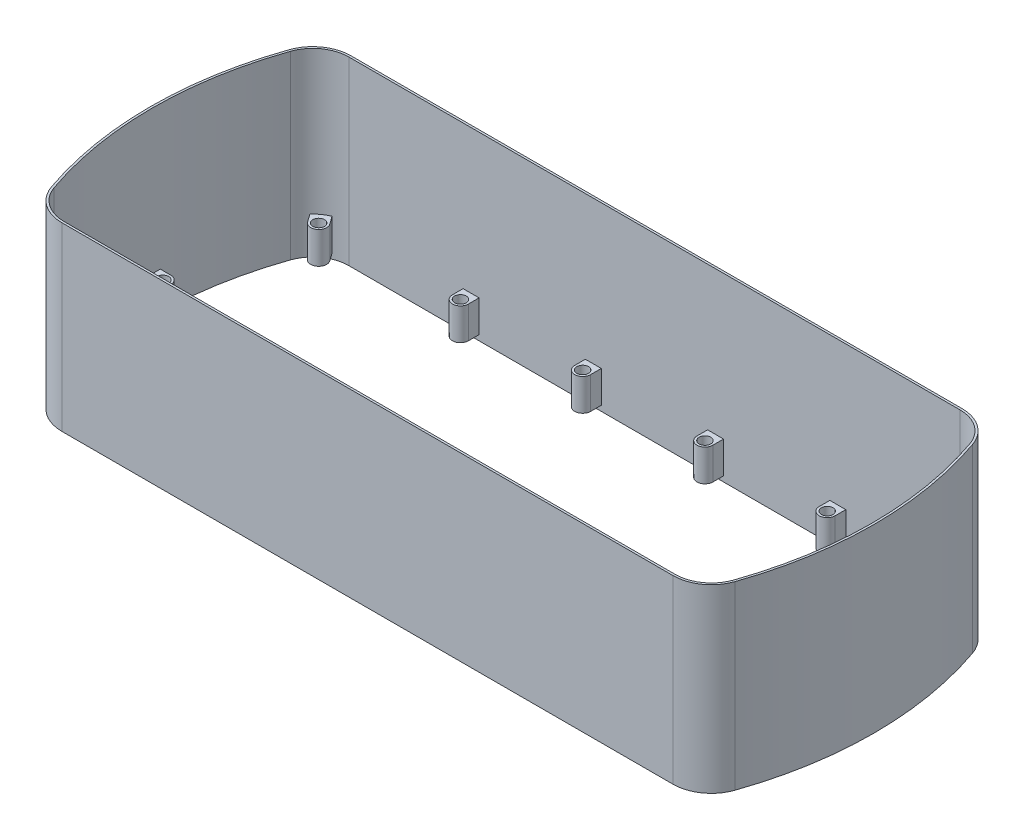
from build123d import *

# Parameters (mm, degrees)
BOSS_EXTRUDE1_DEPTH    = 170
BOSS_EXTRUDE4_START    = 5
SKETCH3_R              = 5.5
BOSS_EXTRUDE4_DEPTH    = 30
BOSS_EXTRUDE5_START    = 16
SKETCH3_4_R            = 5.5
SKETCH3_4_R_2          = 3
BOSS_EXTRUDE5_DEPTH    = 5
BOSS_EXTRUDE5_2_DEPTH  = 5
BOSS_EXTRUDE5_3_DEPTH  = 5
BOSS_EXTRUDE5_4_DEPTH  = 5
BOSS_EXTRUDE5_5_DEPTH  = 5
BOSS_EXTRUDE5_6_DEPTH  = 5
BOSS_EXTRUDE5_7_DEPTH  = 5
BOSS_EXTRUDE5_8_DEPTH  = 5
BOSS_EXTRUDE5_9_DEPTH  = 5
BOSS_EXTRUDE5_10_DEPTH = 5
BOSS_EXTRUDE5_11_DEPTH = 5
BOSS_EXTRUDE5_12_DEPTH = 5
BOSS_EXTRUDE5_13_DEPTH = 5
BOSS_EXTRUDE5_14_DEPTH = 5


with BuildPart() as part:
    # Sketch2 → Boss-Extrude1 (new body)
    with BuildSketch(Plane(origin=(0, 0, 0), x_dir=(1, 0, 0), z_dir=(0, 1, 0))):
        with BuildLine():
            Line((287.5, 136), (-287.5, 136))
            ThreePointArc((-287.5, 136), (-308.359497478, 129.340779897), (-321.501884681, 111.826742498))
            ThreePointArc((-321.501884681, 111.826742498), (-340.394891547, 0), (-321.501884681, -111.826742498))
            ThreePointArc((-321.501884681, -111.826742498), (-308.359497478, -129.340779897), (-287.5, -136))
            Line((-287.5, -136), (287.5, -136))
            ThreePointArc((287.5, -136), (308.359497478, -129.340779897), (321.501884681, -111.826742498))
            ThreePointArc((321.501884681, -111.826742498), (340.394891547, 0), (321.501884681, 111.826742498))
            ThreePointArc((321.501884681, 111.826742498), (308.359497478, 129.340779897), (287.5, 136))
        make_face()
        with BuildLine():
            Line((287.5, -134), (-287.5, -134))
            ThreePointArc((-287.5, -134), (-307.200636507, -127.710736569), (-319.612891088, -111.169701248))
            ThreePointArc((-319.612891088, -111.169701248), (-338.394891547, 0), (-319.612891088, 111.169701248))
            ThreePointArc((-319.612891088, 111.169701248), (-307.200636507, 127.710736569), (-287.5, 134))
            Line((-287.5, 134), (287.5, 134))
            ThreePointArc((287.5, 134), (307.200636507, 127.710736569), (319.612891088, 111.169701248))
            ThreePointArc((319.612891088, 111.169701248), (338.394891547, 0), (319.612891088, -111.169701248))
            ThreePointArc((319.612891088, -111.169701248), (307.200636507, -127.710736569), (287.5, -134))
        make_face(mode=Mode.SUBTRACT)
    extrude(amount=BOSS_EXTRUDE1_DEPTH)

    # Sketch3 → Boss-Extrude4 (add)
    # profile 1 of 14: a face of its own
    with BuildSketch(Plane(origin=(0, 0, 0), x_dir=(1, 0, 0), z_dir=(0, 1, 0)).offset(BOSS_EXTRUDE4_START)):
        with BuildLine():
            Line((-165, -135), (-165, -124))
            ThreePointArc((-165, -124), (-172.5, -116.5), (-180, -124))
            Line((-180, -124), (-180, -135))
            Line((-180, -135), (-165, -135))
        make_face()
        with Locations((-172.5, -124)):
            Circle(SKETCH3_R, mode=Mode.SUBTRACT)
    # profile 2 of 14: a face of its own
    with BuildSketch(Plane(origin=(0, 0, 0), x_dir=(1, 0, 0), z_dir=(0, 1, 0)).offset(BOSS_EXTRUDE4_START)):
        with BuildLine():
            ThreePointArc((-313.38134059, -123.561753103), (-307.780066993, -128.525758233), (-301.251446146, -132.185365135))
            Line((-301.251446146, -132.185365135), (-295.31876639, -123.941335971))
            ThreePointArc((-295.31876639, -123.941335971), (-297.060603011, -113.447857453), (-307.543889113, -115.250022464))
            Line((-307.543889113, -115.250022464), (-313.38134059, -123.561753103))
        make_face()
        with Locations((-301.406331652, -119.560519931)):
            Circle(SKETCH3_R, mode=Mode.SUBTRACT)
    # profile 3 of 14: a face of its own
    with BuildSketch(Plane(origin=(0, 0, 0), x_dir=(1, 0, 0), z_dir=(0, 1, 0)).offset(BOSS_EXTRUDE4_START)):
        with BuildLine():
            Line((-65, -124), (-65, -135))
            Line((-65, -135), (-50, -135))
            Line((-50, -135), (-50, -124))
            ThreePointArc((-50, -124), (-57.5, -116.5), (-65, -124))
        make_face()
        with Locations((-57.5, -124)):
            Circle(SKETCH3_R, mode=Mode.SUBTRACT)
    # profile 4 of 14: a face of its own
    with BuildSketch(Plane(origin=(0, 0, 0), x_dir=(1, 0, 0), z_dir=(0, 1, 0)).offset(BOSS_EXTRUDE4_START)):
        with BuildLine():
            Line((50, -124), (50, -135))
            Line((50, -135), (65, -135))
            Line((65, -135), (65, -124))
            ThreePointArc((65, -124), (57.5, -116.5), (50, -124))
        make_face()
        with Locations((57.5, -124)):
            Circle(SKETCH3_R, mode=Mode.SUBTRACT)
    # profile 5 of 14: a face of its own
    with BuildSketch(Plane(origin=(0, 0, 0), x_dir=(1, 0, 0), z_dir=(0, 1, 0)).offset(BOSS_EXTRUDE4_START)):
        with BuildLine():
            ThreePointArc((-339.312013357, 7.5), (-339.394891547, 0), (-339.312013357, -7.5))
            Line((-339.312013357, -7.5), (-328.394891547, -7.5))
            ThreePointArc((-328.394891547, -7.5), (-320.894891547, 0), (-328.394891547, 7.5))
            Line((-328.394891547, 7.5), (-339.312013357, 7.5))
        make_face()
        with Locations((-328.394891547, 0)):
            Circle(SKETCH3_R, mode=Mode.SUBTRACT)
    # profile 6 of 14: a face of its own
    with BuildSketch(Plane(origin=(0, 0, 0), x_dir=(1, 0, 0), z_dir=(0, 1, 0)).offset(BOSS_EXTRUDE4_START)):
        with BuildLine():
            Line((165, -124), (165, -135))
            Line((165, -135), (180, -135))
            Line((180, -135), (180, -124))
            ThreePointArc((180, -124), (172.5, -116.5), (165, -124))
        make_face()
        with Locations((172.5, -124)):
            Circle(SKETCH3_R, mode=Mode.SUBTRACT)
    # profile 7 of 14: a face of its own
    with BuildSketch(Plane(origin=(0, 0, 0), x_dir=(1, 0, 0), z_dir=(0, 1, 0)).offset(BOSS_EXTRUDE4_START)):
        with BuildLine():
            ThreePointArc((-301.251446146, 132.185365135), (-307.780066993, 128.525758233), (-313.38134059, 123.561753103))
            Line((-313.38134059, 123.561753103), (-307.543889113, 115.250022464))
            ThreePointArc((-307.543889113, 115.250022464), (-297.060603011, 113.447857453), (-295.31876639, 123.941335971))
            Line((-295.31876639, 123.941335971), (-301.251446146, 132.185365135))
        make_face()
        with Locations((-301.406331652, 119.560519931)):
            Circle(SKETCH3_R, mode=Mode.SUBTRACT)
    # profile 8 of 14: a face of its own
    with BuildSketch(Plane(origin=(0, 0, 0), x_dir=(1, 0, 0), z_dir=(0, 1, 0)).offset(BOSS_EXTRUDE4_START)):
        with BuildLine():
            Line((295.31876639, -123.941335971), (301.251446146, -132.185365135))
            ThreePointArc((301.251446146, -132.185365135), (307.780066993, -128.525758233), (313.38134059, -123.561753103))
            Line((313.38134059, -123.561753103), (307.543889113, -115.250022464))
            ThreePointArc((307.543889113, -115.250022464), (297.060603011, -113.447857453), (295.31876639, -123.941335971))
        make_face()
        with Locations((301.406331652, -119.560519931)):
            Circle(SKETCH3_R, mode=Mode.SUBTRACT)
    # profile 9 of 14: a face of its own
    with BuildSketch(Plane(origin=(0, 0, 0), x_dir=(1, 0, 0), z_dir=(0, 1, 0)).offset(BOSS_EXTRUDE4_START)):
        with BuildLine():
            Line((-165, 135), (-180, 135))
            Line((-180, 135), (-180, 124))
            ThreePointArc((-180, 124), (-172.5, 116.5), (-165, 124))
            Line((-165, 124), (-165, 135))
        make_face()
        with Locations((-172.5, 124)):
            Circle(SKETCH3_R, mode=Mode.SUBTRACT)
    # profile 10 of 14: a face of its own
    with BuildSketch(Plane(origin=(0, 0, 0), x_dir=(1, 0, 0), z_dir=(0, 1, 0)).offset(BOSS_EXTRUDE4_START)):
        with BuildLine():
            Line((328.394891547, -7.5), (339.312013357, -7.5))
            ThreePointArc((339.312013357, -7.5), (339.394891547, 0), (339.312013357, 7.5))
            Line((339.312013357, 7.5), (328.394891547, 7.5))
            ThreePointArc((328.394891547, 7.5), (320.894891547, 0), (328.394891547, -7.5))
        make_face()
        with Locations((328.394891547, 0)):
            Circle(SKETCH3_R, mode=Mode.SUBTRACT)
    # profile 11 of 14: a face of its own
    with BuildSketch(Plane(origin=(0, 0, 0), x_dir=(1, 0, 0), z_dir=(0, 1, 0)).offset(BOSS_EXTRUDE4_START)):
        with BuildLine():
            Line((-50, 135), (-65, 135))
            Line((-65, 135), (-65, 124))
            ThreePointArc((-65, 124), (-57.5, 116.5), (-50, 124))
            Line((-50, 124), (-50, 135))
        make_face()
        with Locations((-57.5, 124)):
            Circle(SKETCH3_R, mode=Mode.SUBTRACT)
    # profile 12 of 14: a face of its own
    with BuildSketch(Plane(origin=(0, 0, 0), x_dir=(1, 0, 0), z_dir=(0, 1, 0)).offset(BOSS_EXTRUDE4_START)):
        with BuildLine():
            Line((65, 135), (50, 135))
            Line((50, 135), (50, 124))
            ThreePointArc((50, 124), (57.5, 116.5), (65, 124))
            Line((65, 124), (65, 135))
        make_face()
        with Locations((57.5, 124)):
            Circle(SKETCH3_R, mode=Mode.SUBTRACT)
    # profile 13 of 14: a face of its own
    with BuildSketch(Plane(origin=(0, 0, 0), x_dir=(1, 0, 0), z_dir=(0, 1, 0)).offset(BOSS_EXTRUDE4_START)):
        with BuildLine():
            Line((307.543889113, 115.250022464), (313.38134059, 123.561753103))
            ThreePointArc((313.38134059, 123.561753103), (307.780066993, 128.525758233), (301.251446146, 132.185365135))
            Line((301.251446146, 132.185365135), (295.31876639, 123.941335971))
            ThreePointArc((295.31876639, 123.941335971), (297.060603011, 113.447857453), (307.543889113, 115.250022464))
        make_face()
        with Locations((301.406331652, 119.560519931)):
            Circle(SKETCH3_R, mode=Mode.SUBTRACT)
    # profile 14 of 14: a face of its own
    with BuildSketch(Plane(origin=(0, 0, 0), x_dir=(1, 0, 0), z_dir=(0, 1, 0)).offset(BOSS_EXTRUDE4_START)):
        with BuildLine():
            Line((180, 135), (165, 135))
            Line((165, 135), (165, 124))
            ThreePointArc((165, 124), (172.5, 116.5), (180, 124))
            Line((180, 124), (180, 135))
        make_face()
        with Locations((172.5, 124)):
            Circle(SKETCH3_R, mode=Mode.SUBTRACT)
    extrude(amount=BOSS_EXTRUDE4_DEPTH)


with BuildPart() as body_2:
    # Sketch3_4 → Boss-Extrude5 (new body)
    with BuildSketch(Plane(origin=(0, 0, 0), x_dir=(1, 0, 0), z_dir=(0, 1, 0)).offset(BOSS_EXTRUDE5_START)):
        with Locations((328.394891547, 0)):
            Circle(SKETCH3_4_R)
        with Locations((328.394891547, 0)):
            Circle(SKETCH3_4_R_2, mode=Mode.SUBTRACT)
    extrude(amount=BOSS_EXTRUDE5_DEPTH)


with BuildPart() as body_3:
    # Sketch3_4 → Boss-Extrude5 2 (new body)
    with BuildSketch(Plane(origin=(0, 0, 0), x_dir=(1, 0, 0), z_dir=(0, 1, 0)).offset(BOSS_EXTRUDE5_START)):
        with Locations((301.406331652, 119.560519931)):
            Circle(SKETCH3_4_R)
        with Locations((301.406331652, 119.560519931)):
            Circle(SKETCH3_4_R_2, mode=Mode.SUBTRACT)
    extrude(amount=BOSS_EXTRUDE5_2_DEPTH)


with BuildPart() as body_4:
    # Sketch3_4 → Boss-Extrude5 3 (new body)
    with BuildSketch(Plane(origin=(0, 0, 0), x_dir=(1, 0, 0), z_dir=(0, 1, 0)).offset(BOSS_EXTRUDE5_START)):
        with Locations((172.5, 124)):
            Circle(SKETCH3_4_R)
        with Locations((172.5, 124)):
            Circle(SKETCH3_4_R_2, mode=Mode.SUBTRACT)
    extrude(amount=BOSS_EXTRUDE5_3_DEPTH)


with BuildPart() as body_5:
    # Sketch3_4 → Boss-Extrude5 4 (new body)
    with BuildSketch(Plane(origin=(0, 0, 0), x_dir=(1, 0, 0), z_dir=(0, 1, 0)).offset(BOSS_EXTRUDE5_START)):
        with Locations((57.5, 124)):
            Circle(SKETCH3_4_R)
        with Locations((57.5, 124)):
            Circle(SKETCH3_4_R_2, mode=Mode.SUBTRACT)
    extrude(amount=BOSS_EXTRUDE5_4_DEPTH)


with BuildPart() as body_6:
    # Sketch3_4 → Boss-Extrude5 5 (new body)
    with BuildSketch(Plane(origin=(0, 0, 0), x_dir=(1, 0, 0), z_dir=(0, 1, 0)).offset(BOSS_EXTRUDE5_START)):
        with Locations((-57.5, 124)):
            Circle(SKETCH3_4_R)
        with Locations((-57.5, 124)):
            Circle(SKETCH3_4_R_2, mode=Mode.SUBTRACT)
    extrude(amount=BOSS_EXTRUDE5_5_DEPTH)


with BuildPart() as body_7:
    # Sketch3_4 → Boss-Extrude5 6 (new body)
    with BuildSketch(Plane(origin=(0, 0, 0), x_dir=(1, 0, 0), z_dir=(0, 1, 0)).offset(BOSS_EXTRUDE5_START)):
        with Locations((-172.5, 124)):
            Circle(SKETCH3_4_R)
        with Locations((-172.5, 124)):
            Circle(SKETCH3_4_R_2, mode=Mode.SUBTRACT)
    extrude(amount=BOSS_EXTRUDE5_6_DEPTH)


with BuildPart() as body_8:
    # Sketch3_4 → Boss-Extrude5 7 (new body)
    with BuildSketch(Plane(origin=(0, 0, 0), x_dir=(1, 0, 0), z_dir=(0, 1, 0)).offset(BOSS_EXTRUDE5_START)):
        with Locations((-301.406331652, 119.560519931)):
            Circle(SKETCH3_4_R)
        with Locations((-301.406331652, 119.560519931)):
            Circle(SKETCH3_4_R_2, mode=Mode.SUBTRACT)
    extrude(amount=BOSS_EXTRUDE5_7_DEPTH)


with BuildPart() as body_9:
    # Sketch3_4 → Boss-Extrude5 8 (new body)
    with BuildSketch(Plane(origin=(0, 0, 0), x_dir=(1, 0, 0), z_dir=(0, 1, 0)).offset(BOSS_EXTRUDE5_START)):
        with Locations((-328.394891547, 0)):
            Circle(SKETCH3_4_R)
        with Locations((-328.394891547, 0)):
            Circle(SKETCH3_4_R_2, mode=Mode.SUBTRACT)
    extrude(amount=BOSS_EXTRUDE5_8_DEPTH)


with BuildPart() as body_10:
    # Sketch3_4 → Boss-Extrude5 9 (new body)
    with BuildSketch(Plane(origin=(0, 0, 0), x_dir=(1, 0, 0), z_dir=(0, 1, 0)).offset(BOSS_EXTRUDE5_START)):
        with Locations((-172.5, -124)):
            Circle(SKETCH3_4_R)
        with Locations((-172.5, -124)):
            Circle(SKETCH3_4_R_2, mode=Mode.SUBTRACT)
    extrude(amount=BOSS_EXTRUDE5_9_DEPTH)


with BuildPart() as body_11:
    # Sketch3_4 → Boss-Extrude5 10 (new body)
    with BuildSketch(Plane(origin=(0, 0, 0), x_dir=(1, 0, 0), z_dir=(0, 1, 0)).offset(BOSS_EXTRUDE5_START)):
        with Locations((-57.5, -124)):
            Circle(SKETCH3_4_R)
        with Locations((-57.5, -124)):
            Circle(SKETCH3_4_R_2, mode=Mode.SUBTRACT)
    extrude(amount=BOSS_EXTRUDE5_10_DEPTH)


with BuildPart() as body_12:
    # Sketch3_4 → Boss-Extrude5 11 (new body)
    with BuildSketch(Plane(origin=(0, 0, 0), x_dir=(1, 0, 0), z_dir=(0, 1, 0)).offset(BOSS_EXTRUDE5_START)):
        with Locations((57.5, -124)):
            Circle(SKETCH3_4_R)
        with Locations((57.5, -124)):
            Circle(SKETCH3_4_R_2, mode=Mode.SUBTRACT)
    extrude(amount=BOSS_EXTRUDE5_11_DEPTH)


with BuildPart() as body_13:
    # Sketch3_4 → Boss-Extrude5 12 (new body)
    with BuildSketch(Plane(origin=(0, 0, 0), x_dir=(1, 0, 0), z_dir=(0, 1, 0)).offset(BOSS_EXTRUDE5_START)):
        with Locations((172.5, -124)):
            Circle(SKETCH3_4_R)
        with Locations((172.5, -124)):
            Circle(SKETCH3_4_R_2, mode=Mode.SUBTRACT)
    extrude(amount=BOSS_EXTRUDE5_12_DEPTH)


with BuildPart() as body_14:
    # Sketch3_4 → Boss-Extrude5 13 (new body)
    with BuildSketch(Plane(origin=(0, 0, 0), x_dir=(1, 0, 0), z_dir=(0, 1, 0)).offset(BOSS_EXTRUDE5_START)):
        with Locations((301.406331652, -119.560519931)):
            Circle(SKETCH3_4_R)
        with Locations((301.406331652, -119.560519931)):
            Circle(SKETCH3_4_R_2, mode=Mode.SUBTRACT)
    extrude(amount=BOSS_EXTRUDE5_13_DEPTH)


with BuildPart() as body_15:
    # Sketch3_4 → Boss-Extrude5 14 (new body)
    with BuildSketch(Plane(origin=(0, 0, 0), x_dir=(1, 0, 0), z_dir=(0, 1, 0)).offset(BOSS_EXTRUDE5_START)):
        with Locations((-301.406331652, -119.560519931)):
            Circle(SKETCH3_4_R)
        with Locations((-301.406331652, -119.560519931)):
            Circle(SKETCH3_4_R_2, mode=Mode.SUBTRACT)
    extrude(amount=BOSS_EXTRUDE5_14_DEPTH)


solid = Compound([part.part, body_2.part, body_3.part, body_4.part, body_5.part, body_6.part, body_7.part, body_8.part, body_9.part, body_10.part, body_11.part, body_12.part, body_13.part, body_14.part, body_15.part])
